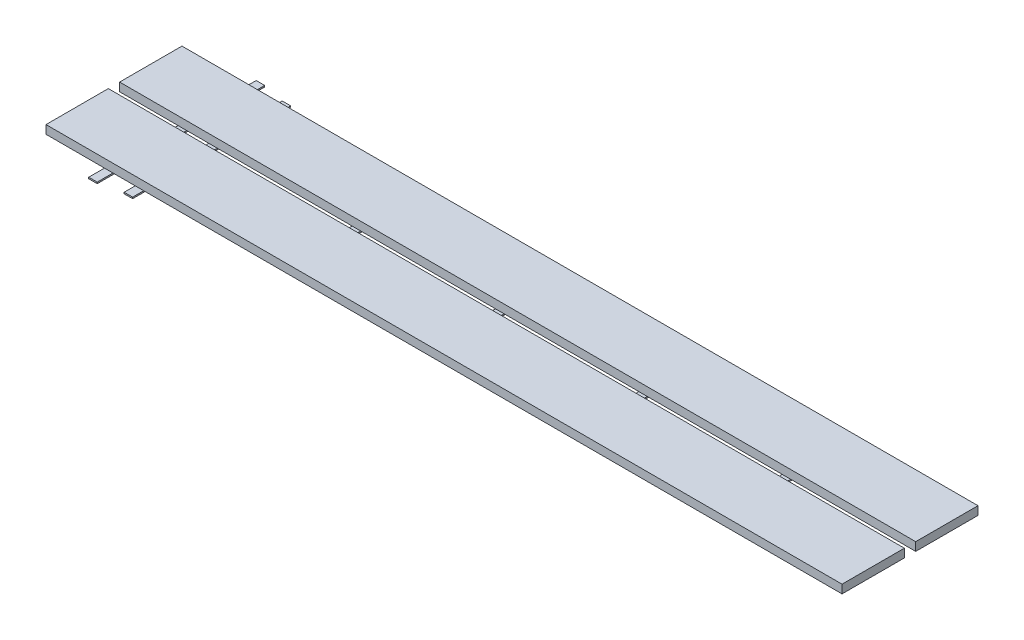
from build123d import *

# Parameters (mm, degrees)
SKETCH2_W             = 19.05
SKETCH2_H             = 355.00056
SKETCH2_R             = 2
BOSS_EXTRUDE1_DEPTH   = 3.175
SKETCH2_H_2           = 251.02058
BOSS_EXTRUDE1_2_DEPTH = 3.175
SKETCH2_H_3           = 177.45456
BOSS_EXTRUDE1_3_DEPTH = 3.175
SKETCH2_H_4           = 125.44806
BOSS_EXTRUDE1_4_DEPTH = 3.175
SKETCH2_H_5           = 88.64092
BOSS_EXTRUDE1_5_DEPTH = 3.175
SKETCH2_H_6           = 376.10796
BOSS_EXTRUDE1_6_DEPTH = 3.175
SKETCH3_W             = 1788.19
SKETCH3_H             = 140
BOSS_EXTRUDE2_DEPTH   = 19


with BuildPart() as part:
    # Sketch2 → Boss-Extrude1 (new body)
    with BuildSketch(Plane(origin=(0, 0, 0), x_dir=(1, 0, 0), z_dir=(0, 1, 0))):
        with Locations((32.525, 177.50028)):
            Rectangle(SKETCH2_W, SKETCH2_H)
        with Locations((32.525, 79.875126)):
            Circle(SKETCH2_R, mode=Mode.SUBTRACT)
        with Locations((32.525, 275.125434)):
            Circle(SKETCH2_R, mode=Mode.SUBTRACT)
    extrude(amount=BOSS_EXTRUDE1_DEPTH)



with BuildPart() as body_2:
    # Sketch2 → Boss-Extrude1 2 (new body)
    with BuildSketch(Plane(origin=(0, 0, 0), x_dir=(1, 0, 0), z_dir=(0, 1, 0))):
        with Locations((354.525, 177.50028)):
            Rectangle(SKETCH2_W, SKETCH2_H_2)
        with Locations((354.525, 108.48022915)):
            Circle(SKETCH2_R, mode=Mode.SUBTRACT)
        with Locations((354.525, 246.52033085)):
            Circle(SKETCH2_R, mode=Mode.SUBTRACT)
    extrude(amount=BOSS_EXTRUDE1_2_DEPTH)


with BuildPart() as body_3:
    # Sketch2 → Boss-Extrude1 3 (new body)
    with BuildSketch(Plane(origin=(0, 0, 0), x_dir=(1, 0, 0), z_dir=(0, 1, 0))):
        with Locations((676.525, 177.50028)):
            Rectangle(SKETCH2_W, SKETCH2_H_3)
        with Locations((676.525, 128.708539125)):
            Circle(SKETCH2_R, mode=Mode.SUBTRACT)
        with Locations((676.525, 226.292020875)):
            Circle(SKETCH2_R, mode=Mode.SUBTRACT)
    extrude(amount=BOSS_EXTRUDE1_3_DEPTH)


with BuildPart() as body_4:
    # Sketch2 → Boss-Extrude1 4 (new body)
    with BuildSketch(Plane(origin=(0, 0, 0), x_dir=(1, 0, 0), z_dir=(0, 1, 0))):
        with Locations((998.525, 177.50028)):
            Rectangle(SKETCH2_W, SKETCH2_H_4)
        with Locations((998.525, 143.008361365)):
            Circle(SKETCH2_R, mode=Mode.SUBTRACT)
        with Locations((998.525, 211.992198635)):
            Circle(SKETCH2_R, mode=Mode.SUBTRACT)
    extrude(amount=BOSS_EXTRUDE1_4_DEPTH)


with BuildPart() as body_5:
    # Sketch2 → Boss-Extrude1 5 (new body)
    with BuildSketch(Plane(origin=(0, 0, 0), x_dir=(1, 0, 0), z_dir=(0, 1, 0))):
        with Locations((1320.525, 177.50028)):
            Rectangle(SKETCH2_W, SKETCH2_H_5)
        with Locations((1320.525, 153.11720963)):
            Circle(SKETCH2_R, mode=Mode.SUBTRACT)
        with Locations((1320.525, 201.88335037)):
            Circle(SKETCH2_R, mode=Mode.SUBTRACT)
    extrude(amount=BOSS_EXTRUDE1_5_DEPTH)


with BuildPart() as body_6:
    # Sketch2 → Boss-Extrude1 6 (new body)
    with BuildSketch(Plane(origin=(0, 0, 0), x_dir=(1, 0, 0), z_dir=(0, 1, 0))):
        with Locations((-36.475, 177.50028)):
            Rectangle(SKETCH2_W, SKETCH2_H_6)
        with Locations((-36.475, 74.070591)):
            Circle(SKETCH2_R, mode=Mode.SUBTRACT)
        with Locations((-36.475, 280.929969)):
            Circle(SKETCH2_R, mode=Mode.SUBTRACT)
    extrude(amount=BOSS_EXTRUDE1_6_DEPTH)


with BuildPart() as part_1:
    add(part.part)

    add(body_2.part)  # Boss-Extrude2 merges body 2

    add(body_3.part)  # Boss-Extrude2 merges body 3

    add(body_4.part)  # Boss-Extrude2 merges body 4

    add(body_5.part)  # Boss-Extrude2 merges body 5

    add(body_6.part)  # Boss-Extrude2 merges body 6
    # Sketch3 → Boss-Extrude2 (add)
    with BuildSketch(Plane(origin=(0, 3.175, 0), x_dir=(1, 0, 0), z_dir=(0, 1, 0))):
        with Locations((716.71, 260.20028)):
            Rectangle(SKETCH3_W, SKETCH3_H)
        with Locations((716.71, 94.80028)):
            Rectangle(SKETCH3_W, SKETCH3_H)
    extrude(amount=BOSS_EXTRUDE2_DEPTH)


solid = part_1.part
